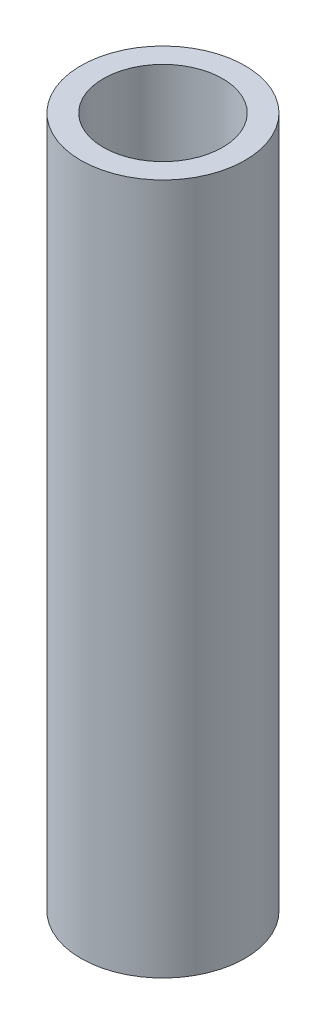
from build123d import *

# Parameters (mm, degrees)
SKETCH1_R           = 4.75
SKETCH1_R_2         = 3.45
BOSS_EXTRUDE1_DEPTH = 20


with BuildPart() as part:
    # Sketch1 → Boss-Extrude1 (new body, symmetric)
    with BuildSketch(Plane(origin=(0, 0, 0), x_dir=(1, 0, 0), z_dir=(0, 1, 0))):
        Circle(SKETCH1_R)
        Circle(SKETCH1_R_2, mode=Mode.SUBTRACT)
    extrude(amount=BOSS_EXTRUDE1_DEPTH, both=True)


solid = part.part
